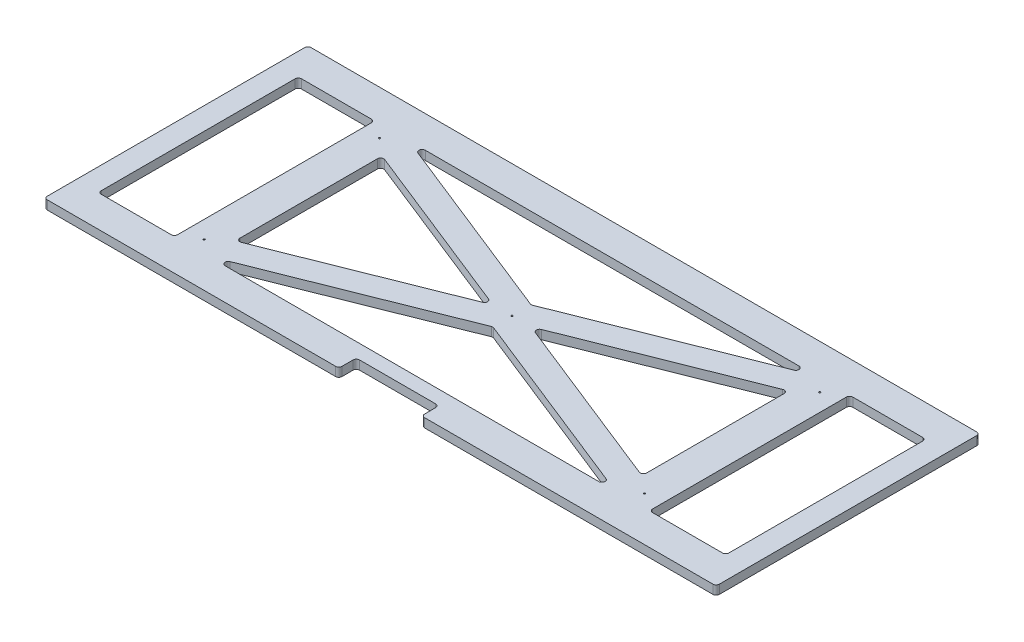
from build123d import *

# Parameters (mm, degrees)
SKETCH1_W                    = 1343.025
SKETCH1_H                    = 527.05
BOSS_EXTRUDE1_DEPTH          = 17.78
FILLET1_R                    = 6.35
SKETCH5_W                    = 152.4
SKETCH5_H                    = 400.05
CUT_EXTRUDE1_DEPTH           = 18.78
F_1_8_0_125_DIAMETER_HOLE2_D = 3.175
CUT_EXTRUDE2_DEPTH           = 18.78
FILLET2_R                    = 6.35


with BuildPart() as part:
    # Sketch1 → Boss-Extrude1 (new body)
    with BuildSketch(Plane(origin=(0, 0, 0), x_dir=(1, 0, 0), z_dir=(0, 1, 0))):
        Rectangle(SKETCH1_W, SKETCH1_H)
    extrude(amount=BOSS_EXTRUDE1_DEPTH)

    # Fillet1
    fillet1_edges = [part.edges().sort_by_distance(p)[0] for p in [
        (671.5125, 8.89, 263.525),
        (-671.5125, 8.89, 263.525),
        (-671.5125, 8.89, -263.525),
        (671.5125, 8.89, -263.525),
    ]]
    fillet(fillet1_edges, radius=FILLET1_R)

    # Sketch5 → Cut-Extrude1 (cut, through all)
    with BuildSketch(Plane(origin=(0, 17.78, 0), x_dir=(1, 0, 0), z_dir=(0, 1, 0))):
        Polygon((-406.4, 200.025), (406.4, 200.025), (0, 38.1), align=None)
        Polygon((0, -38.1), (-406.4, -200.025), (406.4, -200.025), align=None)
        Polygon((406.4, 146.74453125), (406.4, -146.74453125), (38.1, 0), align=None)
        Polygon((-406.4, 146.74453125), (-38.1, 0), (-406.4, -146.74453125), align=None)
        with Locations((550.8625, 0)):
            Rectangle(SKETCH5_W, SKETCH5_H)
        with Locations((-550.8625, 0)):
            Rectangle(SKETCH5_W, SKETCH5_H)
    extrude(amount=-CUT_EXTRUDE1_DEPTH, mode=Mode.SUBTRACT)

    # 1/8 (0.125) Diameter Hole2 (through all)
    with Locations(Plane(origin=(0, 17.78, 0), x_dir=(1, 0, 0), z_dir=(0, 1, 0))):
        with Locations((0, 0), (-439.865615282, -175.258956089), (439.865615282, 175.258956089), (439.865615282, -175.258956089), (-439.865615282, 175.258956089)):
            Hole(F_1_8_0_125_DIAMETER_HOLE2_D / 2)

    # Sketch8 → Cut-Extrude2 (cut, through all)
    with BuildSketch(Plane(origin=(0, 17.78, 0), x_dir=(1, 0, 0), z_dir=(0, 1, 0))):
        with BuildLine():
            Line((-82.55, -263.525), (-82.55, -234.95))
            ThreePointArc((-82.55, -234.95), (-80.690128061, -230.459871939), (-76.2, -228.6))
            Line((-76.2, -228.6), (76.2, -228.6))
            ThreePointArc((76.2, -228.6), (80.690128061, -230.459871939), (82.55, -234.95))
            Line((82.55, -234.95), (82.55, -263.525))
            Line((82.55, -263.525), (-82.55, -263.525))
        make_face()
    extrude(amount=-CUT_EXTRUDE2_DEPTH, mode=Mode.SUBTRACT)

    # Fillet2
    fillet2_edges = [part.edges().sort_by_distance(p)[0] for p in [
        (82.55, 8.89, 263.525),
        (-82.55, 8.89, 263.525),
        (406.4, 8.89, -200.025),
        (0, 8.89, -38.1),
        (-406.4, 8.89, -200.025),
        (-474.6625, 8.89, -200.025),
        (-474.6625, 8.89, 200.025),
        (-627.0625, 8.89, 200.025),
        (-627.0625, 8.89, -200.025),
        (-406.4, 8.89, 146.74453125),
        (-406.4, 8.89, -146.74453125),
        (-38.1, 8.89, 0),
        (627.0625, 8.89, -200.025),
        (627.0625, 8.89, 200.025),
        (474.6625, 8.89, 200.025),
        (474.6625, 8.89, -200.025),
        (0, 8.89, 38.1),
        (406.4, 8.89, 200.025),
        (-406.4, 8.89, 200.025),
        (38.1, 8.89, 0),
        (406.4, 8.89, -146.74453125),
        (406.4, 8.89, 146.74453125),
    ]]
    fillet(fillet2_edges, radius=FILLET2_R)


solid = part.part
